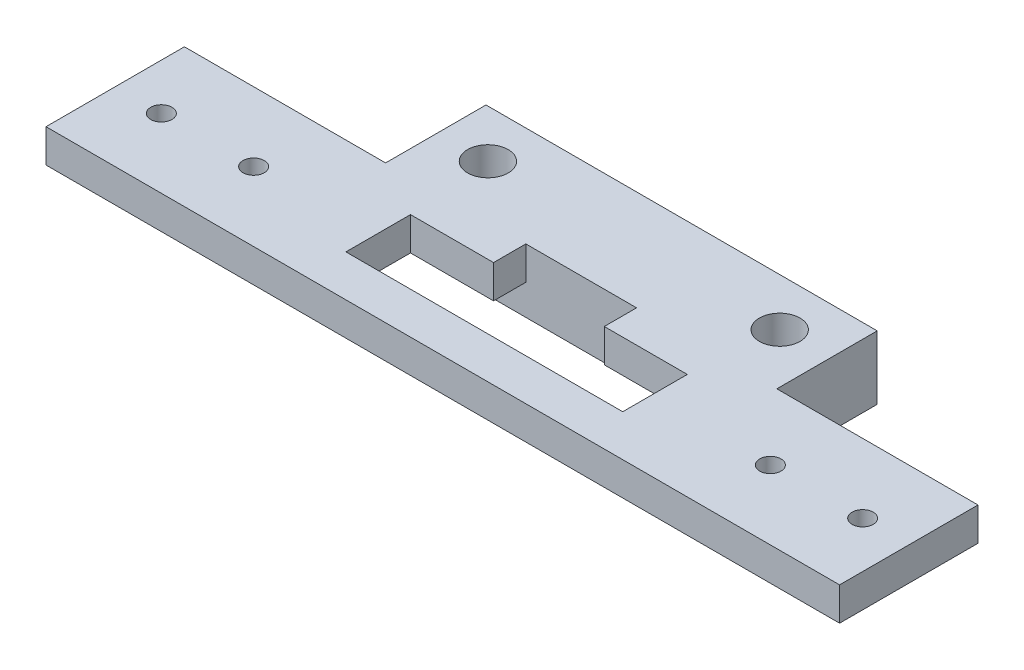
from build123d import *

# Parameters (mm, degrees)
SKETCH1_R           = 1.15
SKETCH1_R_2         = 2.2
BOSS_EXTRUDE2_DEPTH = 3.6
SKETCH2_W           = 42.4
SKETCH2_H           = 10.88
BOSS_EXTRUDE3_DEPTH = 3.3


with BuildPart() as part:
    # Sketch1 → Boss-Extrude2 (new body)
    with BuildSketch(Plane(origin=(0, 0, 0), x_dir=(1, 0, 0), z_dir=(0, 1, 0))):
        Polygon((33, 7.5), (21.2, 7.5), (21.2, 18.38), (-21.2, 18.38), (-21.2, 7.5), (-33, 7.5), (-43, 7.5), (-43, -7.5), (43, -7.5), (43, 7.5), align=None)
        Polygon((-15, -3), (-15, 4), (-6, 4), (-6, 7.5), (0, 7.5), (6, 7.5), (6, 4), (15, 4), (15, -3), align=None, mode=Mode.SUBTRACT)
        with Locations((-38, 0)):
            Circle(SKETCH1_R, mode=Mode.SUBTRACT)
        with Locations((-28, 0)):
            Circle(SKETCH1_R, mode=Mode.SUBTRACT)
        with Locations((28, 0)):
            Circle(SKETCH1_R, mode=Mode.SUBTRACT)
        with Locations((38, 0)):
            Circle(SKETCH1_R, mode=Mode.SUBTRACT)
        with Locations((-15.81, 13.2)):
            Circle(SKETCH1_R_2, mode=Mode.SUBTRACT)
        with Locations((15.81, 13.2)):
            Circle(SKETCH1_R_2, mode=Mode.SUBTRACT)
    extrude(amount=BOSS_EXTRUDE2_DEPTH)

    # Sketch2 → Boss-Extrude3 (add)
    with BuildSketch(Plane.XZ):
        with Locations((0, -12.94)):
            Rectangle(SKETCH2_W, SKETCH2_H)
        Polygon((-11.768548116, -13.2), (-13.789274058, -9.7), (-17.830725942, -9.7), (-19.851451884, -13.2), (-17.830725942, -16.7), (-13.789274058, -16.7), align=None, mode=Mode.SUBTRACT)
        Polygon((19.851451884, -13.2), (17.830725942, -9.7), (13.789274058, -9.7), (11.768548116, -13.2), (13.789274058, -16.7), (17.830725942, -16.7), align=None, mode=Mode.SUBTRACT)
    extrude(amount=BOSS_EXTRUDE3_DEPTH)


solid = part.part
